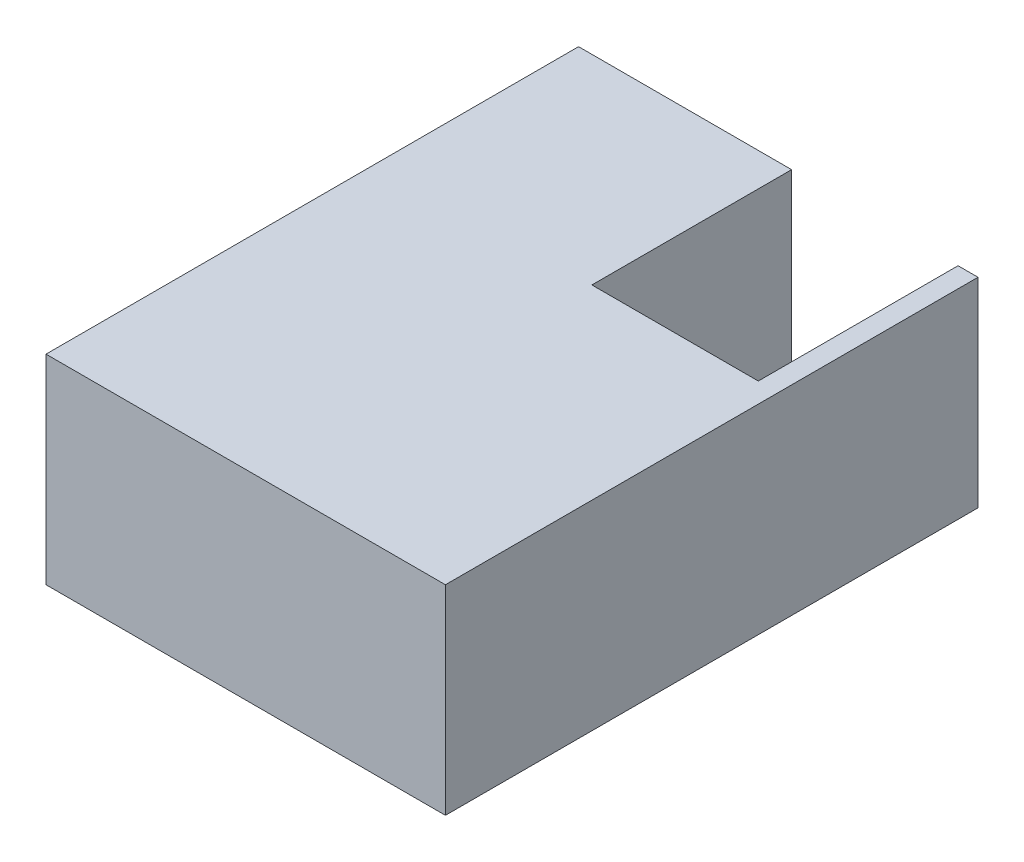
from build123d import *

# Parameters (mm, degrees)
SKETCH1_W           = 600
SKETCH1_H           = 800
BOSS_EXTRUDE1_DEPTH = 300
SKETCH2_W           = 250
SKETCH2_H           = 300
CUT_EXTRUDE1_DEPTH  = 301


with BuildPart() as part:
    # Sketch1 → Boss-Extrude1 (new body)
    with BuildSketch(Plane(origin=(0, 0, 0), x_dir=(1, 0, 0), z_dir=(0, 1, 0))):
        with Locations((300, -400)):
            Rectangle(SKETCH1_W, SKETCH1_H)
    extrude(amount=BOSS_EXTRUDE1_DEPTH)

    # Sketch2 → Cut-Extrude1 (cut, through all)
    with BuildSketch(Plane(origin=(0, 300, 0), x_dir=(1, 0, 0), z_dir=(0, 1, 0))):
        with Locations((445, -150)):
            Rectangle(SKETCH2_W, SKETCH2_H)
    extrude(amount=-CUT_EXTRUDE1_DEPTH, mode=Mode.SUBTRACT)


solid = part.part
